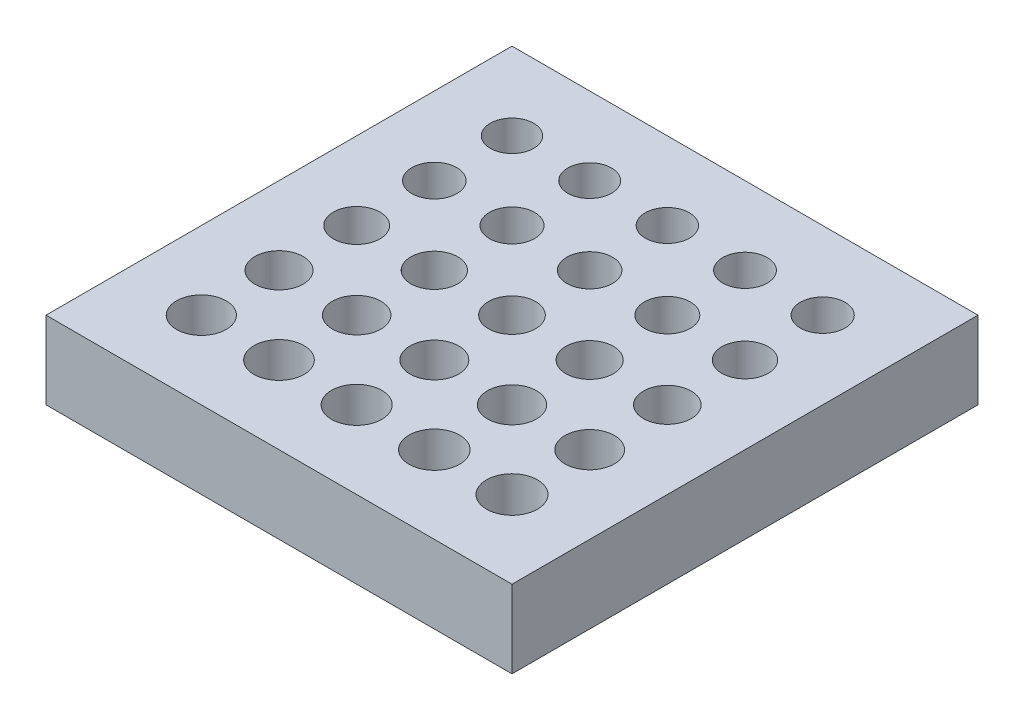
from build123d import *

# Parameters (mm, degrees)
SKETCH1_W           = 38.1
SKETCH1_H           = 38.1
SKETCH1_R           = 1.778
SKETCH1_R_2         = 1.7907
SKETCH1_R_3         = 1.8034
SKETCH1_R_4         = 1.8161
SKETCH1_R_5         = 1.8288
SKETCH1_R_6         = 1.8542
SKETCH1_R_7         = 1.8669
SKETCH1_R_8         = 1.8796
SKETCH1_R_9         = 1.8923
SKETCH1_R_10        = 1.9177
SKETCH1_R_11        = 1.9304
SKETCH1_R_12        = 1.9431
SKETCH1_R_13        = 1.9558
SKETCH1_R_14        = 1.9812
SKETCH1_R_15        = 1.9939
SKETCH1_R_16        = 2.0066
SKETCH1_R_17        = 2.0193
SKETCH1_R_18        = 2.0447
SKETCH1_R_19        = 2.0574
SKETCH1_R_20        = 2.0701
SKETCH1_R_21        = 2.0828
SKETCH1_R_22        = 1.8415
SKETCH1_R_23        = 1.905
SKETCH1_R_24        = 1.9685
SKETCH1_R_25        = 2.032
BOSS_EXTRUDE1_DEPTH = 6.35


with BuildPart() as part:
    # Sketch1 → Boss-Extrude1 (new body)
    with BuildSketch(Plane(origin=(0, 0, 0), x_dir=(1, 0, 0), z_dir=(0, 1, 0))):
        Rectangle(SKETCH1_W, SKETCH1_H)
        with Locations((-12.7, 12.7)):
            Circle(SKETCH1_R, mode=Mode.SUBTRACT)
        with Locations((-6.35, 12.7)):
            Circle(SKETCH1_R_2, mode=Mode.SUBTRACT)
        with Locations((0, 12.7)):
            Circle(SKETCH1_R_3, mode=Mode.SUBTRACT)
        with Locations((6.35, 12.7)):
            Circle(SKETCH1_R_4, mode=Mode.SUBTRACT)
        with Locations((12.7, 12.7)):
            Circle(SKETCH1_R_5, mode=Mode.SUBTRACT)
        with Locations((-6.35, 6.35)):
            Circle(SKETCH1_R_6, mode=Mode.SUBTRACT)
        with Locations((0, 6.35)):
            Circle(SKETCH1_R_7, mode=Mode.SUBTRACT)
        with Locations((6.35, 6.35)):
            Circle(SKETCH1_R_8, mode=Mode.SUBTRACT)
        with Locations((12.7, 6.35)):
            Circle(SKETCH1_R_9, mode=Mode.SUBTRACT)
        with Locations((-6.35, 0)):
            Circle(SKETCH1_R_10, mode=Mode.SUBTRACT)
        Circle(SKETCH1_R_11, mode=Mode.SUBTRACT)
        with Locations((6.35, 0)):
            Circle(SKETCH1_R_12, mode=Mode.SUBTRACT)
        with Locations((12.7, 0)):
            Circle(SKETCH1_R_13, mode=Mode.SUBTRACT)
        with Locations((-6.35, -6.35)):
            Circle(SKETCH1_R_14, mode=Mode.SUBTRACT)
        with Locations((0, -6.35)):
            Circle(SKETCH1_R_15, mode=Mode.SUBTRACT)
        with Locations((6.35, -6.35)):
            Circle(SKETCH1_R_16, mode=Mode.SUBTRACT)
        with Locations((12.7, -6.35)):
            Circle(SKETCH1_R_17, mode=Mode.SUBTRACT)
        with Locations((-6.35, -12.7)):
            Circle(SKETCH1_R_18, mode=Mode.SUBTRACT)
        with Locations((0, -12.7)):
            Circle(SKETCH1_R_19, mode=Mode.SUBTRACT)
        with Locations((6.35, -12.7)):
            Circle(SKETCH1_R_20, mode=Mode.SUBTRACT)
        with Locations((12.7, -12.7)):
            Circle(SKETCH1_R_21, mode=Mode.SUBTRACT)
        with Locations((-12.7, 6.35)):
            Circle(SKETCH1_R_22, mode=Mode.SUBTRACT)
        with Locations((-12.7, 0)):
            Circle(SKETCH1_R_23, mode=Mode.SUBTRACT)
        with Locations((-12.7, -6.35)):
            Circle(SKETCH1_R_24, mode=Mode.SUBTRACT)
        with Locations((-12.7, -12.7)):
            Circle(SKETCH1_R_25, mode=Mode.SUBTRACT)
    extrude(amount=BOSS_EXTRUDE1_DEPTH)


solid = part.part
